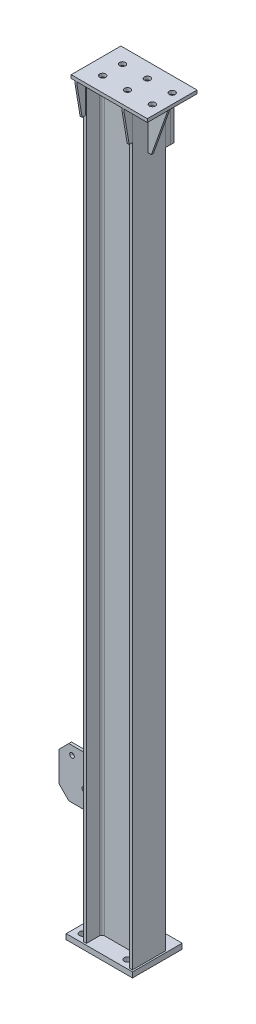
from build123d import *

# Parameters (mm, degrees)
H_HM150_100_5_DEPTH = 2263
SKETCH_12_W         = 200
SKETCH_12_H         = 150
EXTRUDE_1_DEPTH     = 16
SKETCH_13_W         = 230
SKETCH_13_H         = 150
EXTRUDE_2_DEPTH     = 10
SKETCH_14_R         = 9
CUT_EXTRUDE_1_DEPTH = 10
SKETCH_16_W         = 8
SKETCH_16_H         = 150
EXTRUDE_4_DEPTH     = 120
CHAMFER_1_SIZE      = 30
SKETCH_17_R         = 7
CUT_EXTRUDE_2_DEPTH = 8
EXTRUDE_5_DEPTH     = 6
EXTRUDE_6_DEPTH     = 6
SKETCH_19_W         = 15
SKETCH_19_H         = 163
EXTRUDE_6_2_DEPTH   = 6
EXTRUDE_7_DEPTH     = 6
SKETCH_20_W         = 15
SKETCH_20_H         = 163
EXTRUDE_7_2_DEPTH   = 6
SKETCH_21_W         = 10
SKETCH_21_H         = 148
EXTRUDE_8_DEPTH     = 148
SKETCH_22_R         = 10
CUT_EXTRUDE_3_DEPTH = 16


with BuildPart() as part:
    # 草图11 → H型钢 HM150×100(5) (new body)
    with BuildSketch(Plane.ZX):
        with BuildLine():
            Line((-50, -74), (50, -74))
            Line((50, -74), (50, -65))
            Line((50, -65), (11, -65))
            ThreePointArc((11, -65), (5.343145751, -62.656854249), (3, -57))
            Line((3, -57), (3, 57))
            ThreePointArc((3, 57), (5.343145751, 62.656854249), (11, 65))
            Line((11, 65), (50, 65))
            Line((50, 65), (50, 74))
            Line((50, 74), (-50, 74))
            Line((-50, 74), (-50, 65))
            Line((-50, 65), (-11, 65))
            ThreePointArc((-11, 65), (-5.343145751, 62.656854249), (-3, 57))
            Line((-3, 57), (-3, -57))
            ThreePointArc((-3, -57), (-5.343145751, -62.656854249), (-11, -65))
            Line((-11, -65), (-50, -65))
            Line((-50, -65), (-50, -74))
        make_face()
    extrude(amount=H_HM150_100_5_DEPTH)


with BuildPart() as body_2:
    # 草图12 → 凸台-拉伸1 (new body)
    with BuildSketch(Plane.XZ):
        with Locations((-21, -20)):
            Rectangle(SKETCH_12_W, SKETCH_12_H)
    extrude(amount=EXTRUDE_1_DEPTH)

    # 草图22 → 切除-拉伸3 (cut)
    with BuildSketch(Plane(origin=(0, 0, 0), x_dir=(1, 0, 0), z_dir=(0, 1, 0))):
        with Locations(Location((-96, -30, 0), (0, 0, 270))):
            Circle(SKETCH_22_R)
        with Locations(Location((39, -30, 0), (0, 0, 270))):
            Circle(SKETCH_22_R)
        with Locations(Location((-96, 70, 0), (0, 0, 270))):
            Circle(SKETCH_22_R)
        with Locations(Location((39, 70, 0), (0, 0, 270))):
            Circle(SKETCH_22_R)
    extrude(amount=-CUT_EXTRUDE_3_DEPTH, mode=Mode.SUBTRACT)


with BuildPart() as body_3:
    # 草图13 → 凸台-拉伸2 (new body)
    with BuildSketch(Plane(origin=(0, 2263, 0), x_dir=(1, 0, 0), z_dir=(0, 1, 0))):
        with Locations((29, 0)):
            Rectangle(SKETCH_13_W, SKETCH_13_H)
    extrude(amount=EXTRUDE_2_DEPTH)

    # 草图14 → 切除-拉伸1 (cut)
    with BuildSketch(Plane(origin=(0, 2273, 0), x_dir=(1, 0, 0), z_dir=(0, 1, 0))):
        with Locations(Location((114, 30, 0), (0, 0, 270))):
            Circle(SKETCH_14_R)
        with Locations(Location((114, -30, 0), (0, 0, 270))):
            Circle(SKETCH_14_R)
        with Locations(Location((39, -30, 0), (0, 0, 270))):
            Circle(SKETCH_14_R)
        with Locations(Location((39, 30, 0), (0, 0, 270))):
            Circle(SKETCH_14_R)
        with Locations(Location((-36, 30, 0), (0, 0, 270))):
            Circle(SKETCH_14_R)
        with Locations(Location((-36, -30, 0), (0, 0, 270))):
            Circle(SKETCH_14_R)
    extrude(amount=-CUT_EXTRUDE_1_DEPTH, mode=Mode.SUBTRACT)


with BuildPart() as body_4:
    # 草图16 → 凸台-拉伸4 (new body)
    with BuildSketch(Plane.ZY.offset(74)):
        with Locations((0, 375)):
            Rectangle(SKETCH_16_W, SKETCH_16_H)
    extrude(amount=EXTRUDE_4_DEPTH)

    # 倒角1
    chamfer_1_edges = [body_4.edges().sort_by_distance(p)[0] for p in [
        (-194, 450, 0),
        (-194, 300, 0),
    ]]
    chamfer(chamfer_1_edges, length=CHAMFER_1_SIZE)

    # 草图17 → 切除-拉伸2 (cut)
    with BuildSketch(Plane.XY.offset(4)):
        with Locations((-154.529942738, 423.960866654)):
            Circle(SKETCH_17_R)
        with Locations((-117.590053679, 353)):
            Circle(SKETCH_17_R)
    extrude(amount=-CUT_EXTRUDE_2_DEPTH, mode=Mode.SUBTRACT)


with BuildPart() as body_5:
    # 草图18 → 凸台-拉伸5 (new body)
    with BuildSketch(Plane(origin=(0, 0, -3), x_dir=(-1, 0, 0), z_dir=(0, 0, -1))):
        Polygon((-74, 2263), (-74, 2113), (-84, 2113), (-134, 2253), (-134, 2263), align=None)
    extrude(amount=-EXTRUDE_5_DEPTH)


with BuildPart() as body_6:
    # 草图19 → 凸台-拉伸6 (new body)
    with BuildSketch(Plane(origin=(74, 0, 0), x_dir=(0, 0, -1), z_dir=(1, 0, 0))):
        Polygon((-50, 2263), (-75, 2263), (-75, 2253), (-60, 2163), (-50, 2163), align=None)
    extrude(amount=-EXTRUDE_6_DEPTH)


with BuildPart() as body_7:
    # 草图19 → Extrude 6 2 (new body)
    with BuildSketch(Plane(origin=(74, 0, 0), x_dir=(0, 0, -1), z_dir=(1, 0, 0))):
        with Locations((57.5, 2181.5)):
            Rectangle(SKETCH_19_W, SKETCH_19_H)
    extrude(amount=-EXTRUDE_6_2_DEPTH)


with BuildPart() as body_8:
    # 草图20 → 凸台-拉伸7 (new body)
    with BuildSketch(Plane.ZY.offset(74)):
        Polygon((50, 2263), (50, 2163), (60, 2163), (75, 2253), (75, 2263), align=None)
    extrude(amount=-EXTRUDE_7_DEPTH)


with BuildPart() as body_9:
    # 草图20 → Extrude 7 2 (new body)
    with BuildSketch(Plane.ZY.offset(74)):
        with Locations((-57.5, 2181.5)):
            Rectangle(SKETCH_20_W, SKETCH_20_H)
    extrude(amount=-EXTRUDE_7_2_DEPTH)


with BuildPart() as body_10:
    # 草图21 → 凸台-拉伸8 (new body)
    with BuildSketch(Plane(origin=(74, 0, 0), x_dir=(0, 0, -1), z_dir=(1, 0, 0))):
        with Locations((70, 2174)):
            Rectangle(SKETCH_21_W, SKETCH_21_H)
    extrude(amount=-EXTRUDE_8_DEPTH)


solid = Compound([part.part, body_2.part, body_3.part, body_4.part, body_5.part, body_6.part, body_7.part, body_8.part, body_9.part, body_10.part])
